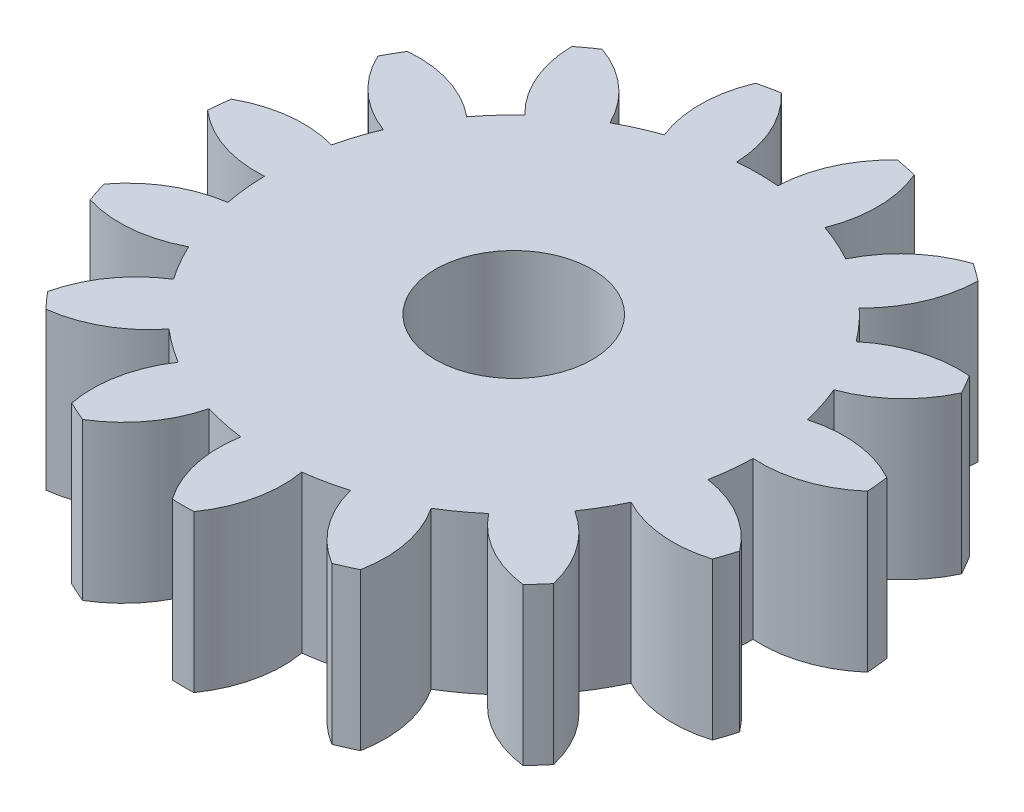
from build123d import *

# Parameters (mm, degrees)
SKETCH1_R           = 1.5875
BOSS_EXTRUDE1_DEPTH = 3.175


with BuildPart() as part:
    # Sketch1 → Boss-Extrude1 (new body)
    with BuildSketch(Plane(origin=(0, 0, 0), x_dir=(1, 0, 0), z_dir=(0, 1, 0))):
        with BuildLine():
            ThreePointArc((-1.625434965, 4.675517209), (-2.013346383, 4.522050015), (-2.386958137, 4.336465249))
            ThreePointArc((-2.386958137, 4.336465249), (-2.952961664, 5.077251852), (-3.758538597, 5.546475243))
            ThreePointArc((-3.758538597, 5.546475243), (-3.93816119, 5.420413862), (-4.113559122, 5.288537733))
            ThreePointArc((-4.113559122, 5.288537733), (-3.916238121, 4.37739054), (-3.386612903, 3.610173548))
            ThreePointArc((-3.386612903, 3.610173548), (-3.678566886, 3.312196501), (-3.944394082, 2.99069479))
            ThreePointArc((-3.944394082, 2.99069479), (-4.762769089, 3.437222652), (-5.689550583, 3.538221892))
            ThreePointArc((-5.689550583, 3.538221892), (-5.802370205, 3.35), (-5.908965335, 3.158184395))
            ThreePointArc((-5.908965335, 3.158184395), (-5.35810668, 2.406067698), (-4.562214704, 1.920598082))
            ThreePointArc((-4.562214704, 1.920598082), (-4.707729756, 1.529634122), (-4.819808456, 1.127806033))
            ThreePointArc((-4.819808456, 1.127806033), (-5.74905047, 1.20286643), (-6.636787586, 0.918177833))
            ThreePointArc((-6.636787586, 0.918177833), (-6.663296699, 0.700340704), (-6.68265776, 0.481752285))
            ThreePointArc((-6.68265776, 0.481752285), (-5.873509917, 0.018713892), (-4.948968136, -0.10106624))
            ThreePointArc((-4.948968136, -0.10106624), (-4.922883382, -0.517415893), (-4.861834162, -0.930090633))
            ThreePointArc((-4.861834162, -0.930090633), (-5.741268797, -1.239476326), (-6.436463722, -1.860627515))
            ThreePointArc((-6.436463722, -1.860627515), (-6.372078659, -2.070413862), (-6.300857949, -2.277979173))
            ThreePointArc((-6.300857949, -2.277979173), (-5.373329931, -2.371875716), (-4.480000018, -2.105255291))
            ThreePointArc((-4.480000018, -2.105255291), (-4.286825749, -2.475), (-4.063204572, -2.827166179))
            ThreePointArc((-4.063204572, -2.827166179), (-4.74076959, -3.467502365), (-5.123216807, -4.317713463))
            ThreePointArc((-5.123216807, -4.317713463), (-4.979070331, -4.483175063), (-4.829582556, -4.643827336))
            ThreePointArc((-4.829582556, -4.643827336), (-3.944052384, -4.352346465), (-3.236399197, -3.745426576))
            ThreePointArc((-3.236399197, -3.745426576), (-2.909536999, -4.004634122), (-2.562009999, -4.235399009))
            ThreePointArc((-2.562009999, -4.235399009), (-2.920548253, -5.095965744), (-2.924119163, -6.028227527))
            ThreePointArc((-2.924119163, -6.028227527), (-2.725135509, -6.120754566), (-2.523228465, -6.206715566))
            ThreePointArc((-2.523228465, -6.206715566), (-1.83281235, -5.58025697), (-1.433195553, -4.737979581))
            ThreePointArc((-1.433195553, -4.737979581), (-1.02916287, -4.841830624), (-0.617820622, -4.911292872))
            ThreePointArc((-0.617820622, -4.911292872), (-0.595337591, -5.84329035), (-0.219414751, -6.696406287))
            ThreePointArc((-0.219414751, -6.696406287), (0, -6.7), (0.219414751, -6.696406287))
            ThreePointArc((0.219414751, -6.696406287), (0.595337591, -5.84329035), (0.617820622, -4.911292872))
            ThreePointArc((0.617820622, -4.911292872), (1.02916287, -4.841830624), (1.433195553, -4.737979581))
            ThreePointArc((1.433195553, -4.737979581), (1.83281235, -5.58025697), (2.523228465, -6.206715566))
            ThreePointArc((2.523228465, -6.206715566), (2.725135509, -6.120754566), (2.924119163, -6.028227527))
            ThreePointArc((2.924119163, -6.028227527), (2.920548253, -5.095965744), (2.562009999, -4.235399009))
            ThreePointArc((2.562009999, -4.235399009), (2.909536999, -4.004634122), (3.236399197, -3.745426576))
            ThreePointArc((3.236399197, -3.745426576), (3.944052384, -4.352346465), (4.829582556, -4.643827336))
            ThreePointArc((4.829582556, -4.643827336), (4.979070331, -4.483175063), (5.123216807, -4.317713463))
            ThreePointArc((5.123216807, -4.317713463), (4.74076959, -3.467502365), (4.063204572, -2.827166179))
            ThreePointArc((4.063204572, -2.827166179), (4.286825749, -2.475), (4.480000018, -2.105255291))
            ThreePointArc((4.480000018, -2.105255291), (5.373329931, -2.371875716), (6.300857949, -2.277979173))
            ThreePointArc((6.300857949, -2.277979173), (6.372078659, -2.070413862), (6.436463722, -1.860627515))
            ThreePointArc((6.436463722, -1.860627515), (5.741268797, -1.239476326), (4.861834162, -0.930090633))
            ThreePointArc((4.861834162, -0.930090633), (4.922883382, -0.517415893), (4.948968136, -0.10106624))
            ThreePointArc((4.948968136, -0.10106624), (5.873509917, 0.018713892), (6.68265776, 0.481752285))
            ThreePointArc((6.68265776, 0.481752285), (6.663296699, 0.700340704), (6.636787586, 0.918177833))
            ThreePointArc((6.636787586, 0.918177833), (5.74905047, 1.20286643), (4.819808456, 1.127806033))
            ThreePointArc((4.819808456, 1.127806033), (4.707729756, 1.529634122), (4.562214704, 1.920598082))
            ThreePointArc((4.562214704, 1.920598082), (5.35810668, 2.406067698), (5.908965335, 3.158184395))
            ThreePointArc((5.908965335, 3.158184395), (5.802370205, 3.35), (5.689550583, 3.538221892))
            ThreePointArc((5.689550583, 3.538221892), (4.762769089, 3.437222652), (3.944394082, 2.99069479))
            ThreePointArc((3.944394082, 2.99069479), (3.678566886, 3.312196501), (3.386612903, 3.610173548))
            ThreePointArc((3.386612903, 3.610173548), (3.916238121, 4.37739054), (4.113559122, 5.288537733))
            ThreePointArc((4.113559122, 5.288537733), (3.93816119, 5.420413862), (3.758538597, 5.546475243))
            ThreePointArc((3.758538597, 5.546475243), (2.952961664, 5.077251852), (2.386958137, 4.336465249))
            ThreePointArc((2.386958137, 4.336465249), (2.013346383, 4.522050015), (1.625434965, 4.675517209))
            ThreePointArc((1.625434965, 4.675517209), (1.797216412, 5.591822791), (1.606881166, 6.504454852))
            ThreePointArc((1.606881166, 6.504454852), (1.393008328, 6.553588925), (1.177641141, 6.595692636))
            ThreePointArc((1.177641141, 6.595692636), (0.632560341, 5.839378081), (0.416795446, 4.93242147))
            ThreePointArc((0.416795446, 4.93242147), (0, 4.95), (-0.416795446, 4.93242147))
            ThreePointArc((-0.416795446, 4.93242147), (-0.632560341, 5.839378081), (-1.177641141, 6.595692636))
            ThreePointArc((-1.177641141, 6.595692636), (-1.393008328, 6.553588925), (-1.606881166, 6.504454852))
            ThreePointArc((-1.606881166, 6.504454852), (-1.797216412, 5.591822791), (-1.625434965, 4.675517209))
        make_face()
        Circle(SKETCH1_R, mode=Mode.SUBTRACT)
    extrude(amount=BOSS_EXTRUDE1_DEPTH)


solid = part.part
